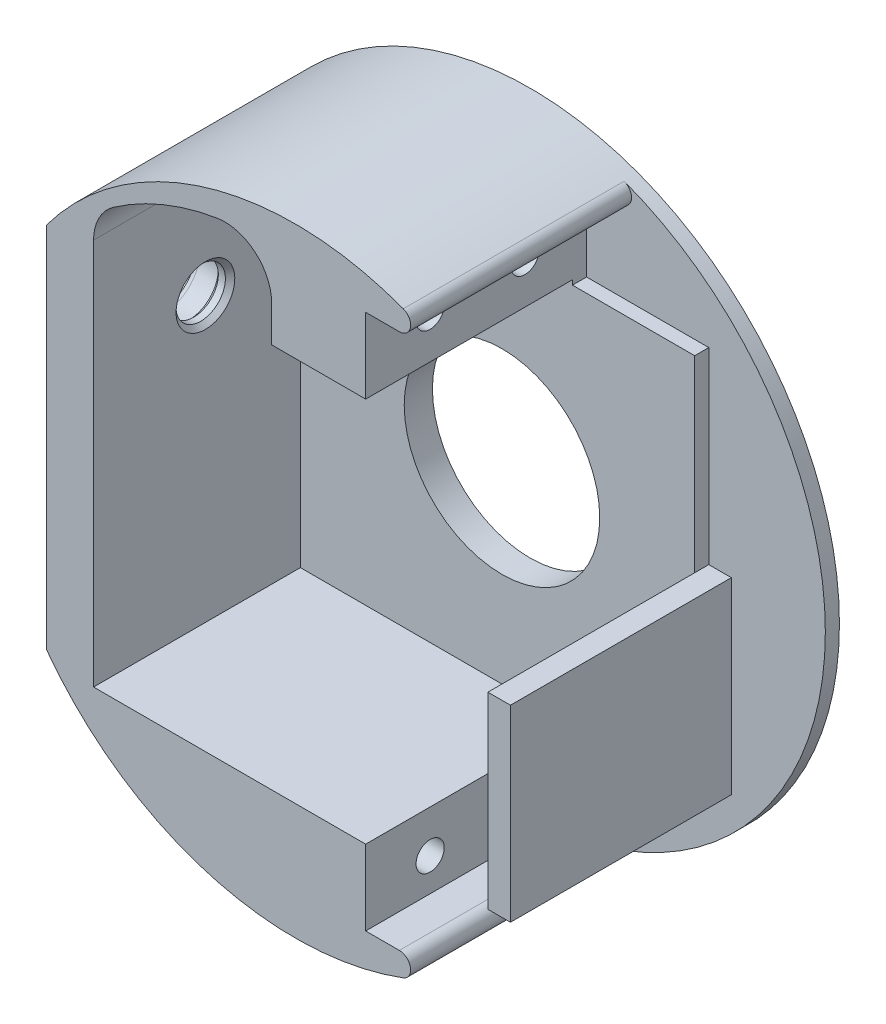
from build123d import *

# Parameters (mm, degrees)
SKETCH2_R           = 32.9
SKETCH2_R_2         = 10.4
BOSS_EXTRUDE1_DEPTH = 25
SKETCH4_W           = 2.4
SKETCH4_H           = 20
CUT_EXTRUDE1_DEPTH  = 22
CUT_EXTRUDE2_DEPTH  = 1.5
SKETCH6_R           = 3.625
CUT_EXTRUDE3_DEPTH  = 3.25
FILLET1_R           = 0.75
CUT_EXTRUDE4_REACH  = 58.098
SKETCH7_R           = 2.625
CHAMFER1_SIZE       = 0.5
SKETCH8_R           = 1.5
CUT_EXTRUDE5_DEPTH  = 8.5
FILLET2_R           = 1.2


with BuildPart() as part:
    # Sketch2 → Boss-Extrude1 (new body)
    with BuildSketch(Plane.XY):
        with Locations((9.62, 10)):
            Circle(SKETCH2_R)
        with Locations((9.62, 10)):
            Circle(SKETCH2_R_2, mode=Mode.SUBTRACT)
    extrude(amount=BOSS_EXTRUDE1_DEPTH)

    # Sketch4 → Cut-Extrude1 (cut)
    with BuildSketch(Plane.XY.offset(25)):
        with BuildLine():
            Line((-11.82822809, -10.5), (17.12, -10.5))
            Line((17.12, -10.5), (17.12, -18.5))
            Line((17.12, -18.5), (26.056544649, -18.5))
            ThreePointArc((26.056544649, -18.5), (42.52, 10), (26.056544649, 38.5))
            Line((26.056544649, 38.5), (17.12, 38.5))
            Line((17.12, 38.5), (17.12, 30.5))
            Line((17.12, 30.5), (7.12, 30.5))
            Line((7.12, 30.5), (7.12, 34.339279361))
            ThreePointArc((7.12, 34.339279361), (5.349790899, 38.156143355), (1.292619701, 39.270348397))
            ThreePointArc((1.292619701, 39.270348397), (-4.45403874, 37.633425382), (-9.697773665, 34.768666365))
            ThreePointArc((-9.697773665, 34.768666365), (-11.263751051, 32.981913664), (-11.82822809, 30.674071368))
            Line((-11.82822809, 30.674071368), (-11.82822809, -10.5))
        make_face()
        with Locations((31.32, 0)):
            Rectangle(SKETCH4_W, SKETCH4_H, mode=Mode.SUBTRACT)
        with BuildLine():
            Line((-16.82822809, -9.567862195), (-16.82822809, 29.567862195))
            ThreePointArc((-16.82822809, 29.567862195), (-23.28, 10), (-16.82822809, -9.567862195))
        make_face()
    extrude(amount=-CUT_EXTRUDE1_DEPTH, mode=Mode.SUBTRACT)

    # Sketch5 → Cut-Extrude2 (cut)
    with BuildSketch(Plane.XY.offset(3)):
        with BuildLine():
            Line((17.12, 38.5), (26.056544649, 38.5))
            ThreePointArc((26.056544649, 38.5), (42.52, 10), (26.056544649, -18.5))
            Line((26.056544649, -18.5), (17.12, -18.5))
            Line((17.12, -18.5), (17.12, -10))
            Line((17.12, -10), (32.52, -10))
            Line((32.52, -10), (32.52, 10))
            Line((32.52, 10), (30.12, 10))
            Line((30.12, 10), (30.12, 30))
            Line((30.12, 30), (17.12, 30))
            Line((17.12, 30), (17.12, 38.5))
        make_face()
        with BuildLine():
            Line((-16.82822809, -9.567862195), (-16.82822809, 29.567862195))
            ThreePointArc((-16.82822809, 29.567862195), (-23.28, 10), (-16.82822809, -9.567862195))
        make_face()
    extrude(amount=-CUT_EXTRUDE2_DEPTH, mode=Mode.SUBTRACT)

    # Sketch6 → Cut-Extrude3 (cut)
    with BuildSketch(Plane.ZY.offset(16.82822809)):
        with Locations((13.1, 19.62)):
            Circle(SKETCH6_R)
    extrude(amount=-CUT_EXTRUDE3_DEPTH, mode=Mode.SUBTRACT)

    # Fillet1
    fillet1_edges = [part.edges().sort_by_distance(p)[0] for p in [
        (-16.82822809, 19.62, 9.475),
    ]]
    fillet(fillet1_edges, radius=FILLET1_R)

    # Sketch7 → Cut-Extrude4 (cut, up to next)
    with BuildSketch(Plane.ZY.offset(13.57822809), mode=Mode.PRIVATE) as cut_extrude4_sk1:
        with Locations((13.1, 19.62)):
            Circle(SKETCH7_R)
    cut_extrude4_tool1 = extrude(cut_extrude4_sk1.sketch, amount=-CUT_EXTRUDE4_REACH, mode=Mode.PRIVATE) & part.part
    add(cut_extrude4_tool1.solids().sort_by_distance((-13.578228, 19.62, 13.1))[0], mode=Mode.SUBTRACT)

    # Chamfer1
    chamfer1_edges = [part.edges().sort_by_distance(p)[0] for p in [
        (-13.57822809, 19.62, 10.475),
        (-11.82822809, 19.62, 10.475),
    ]]
    chamfer(chamfer1_edges, length=CHAMFER1_SIZE)

    # Sketch8 → Cut-Extrude5 (cut)
    with BuildSketch(Plane(origin=(17.12, 0, 0), x_dir=(0, 0, -1), z_dir=(1, 0, 0))):
        with Locations((-18.14, -15)):
            Circle(SKETCH8_R)
        with Locations((-8.06, -15)):
            Circle(SKETCH8_R)
        with Locations((-18.14, 35)):
            Circle(SKETCH8_R)
        with Locations((-8.06, 35)):
            Circle(SKETCH8_R)
    extrude(amount=-CUT_EXTRUDE5_DEPTH, mode=Mode.SUBTRACT)

    # Fillet2
    fillet2_edges = [part.edges().sort_by_distance(p)[0] for p in [
        (26.056544649, -18.5, 13.25),
        (26.056544649, 38.5, 13.25),
    ]]
    fillet(fillet2_edges, radius=FILLET2_R)


solid = part.part
